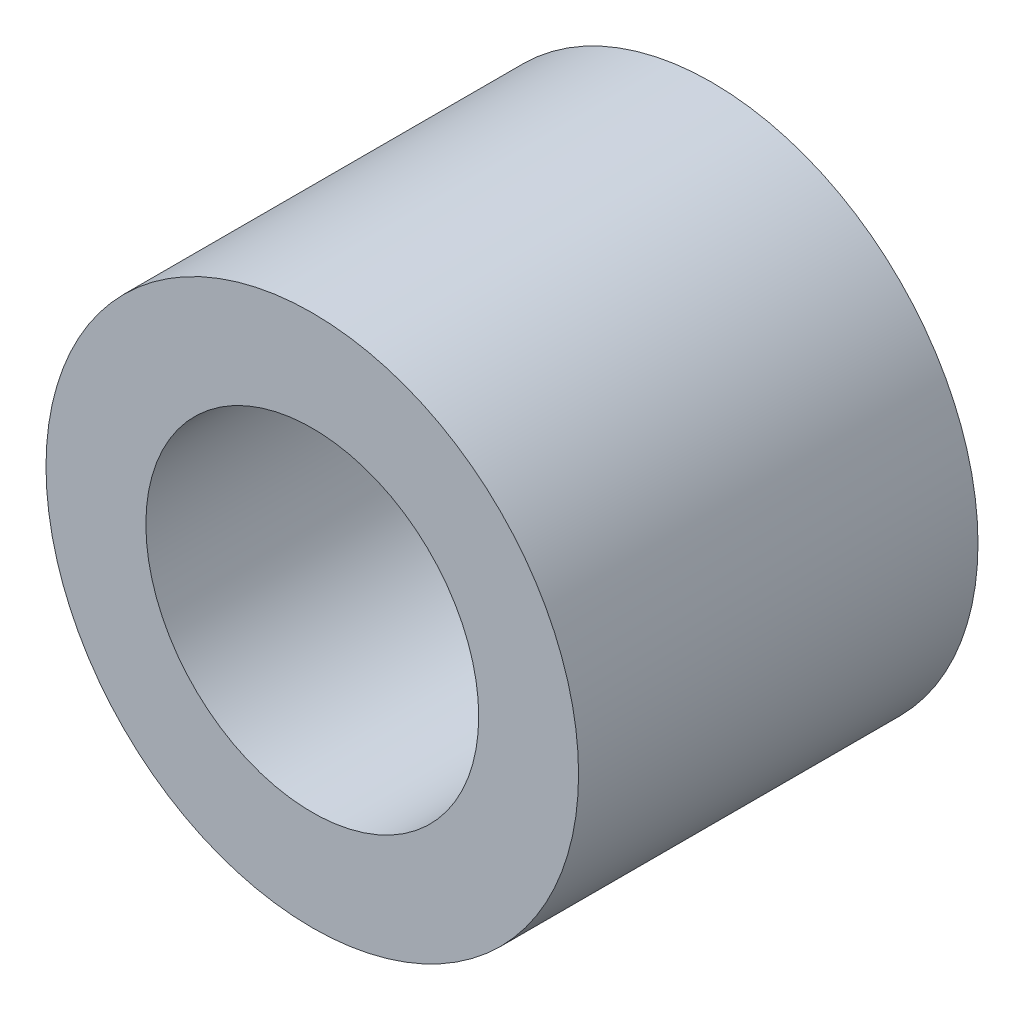
from build123d import *

# Parameters (mm, degrees)
SKETCH_1_R      = 8
SKETCH_1_R_2    = 5
EXTRUDE_1_DEPTH = 12


with BuildPart() as part:
    # 草图1 → 凸台-拉伸1 (new body)
    with BuildSketch(Plane.XY):
        Circle(SKETCH_1_R)
        Circle(SKETCH_1_R_2, mode=Mode.SUBTRACT)
    extrude(amount=EXTRUDE_1_DEPTH)


solid = part.part
